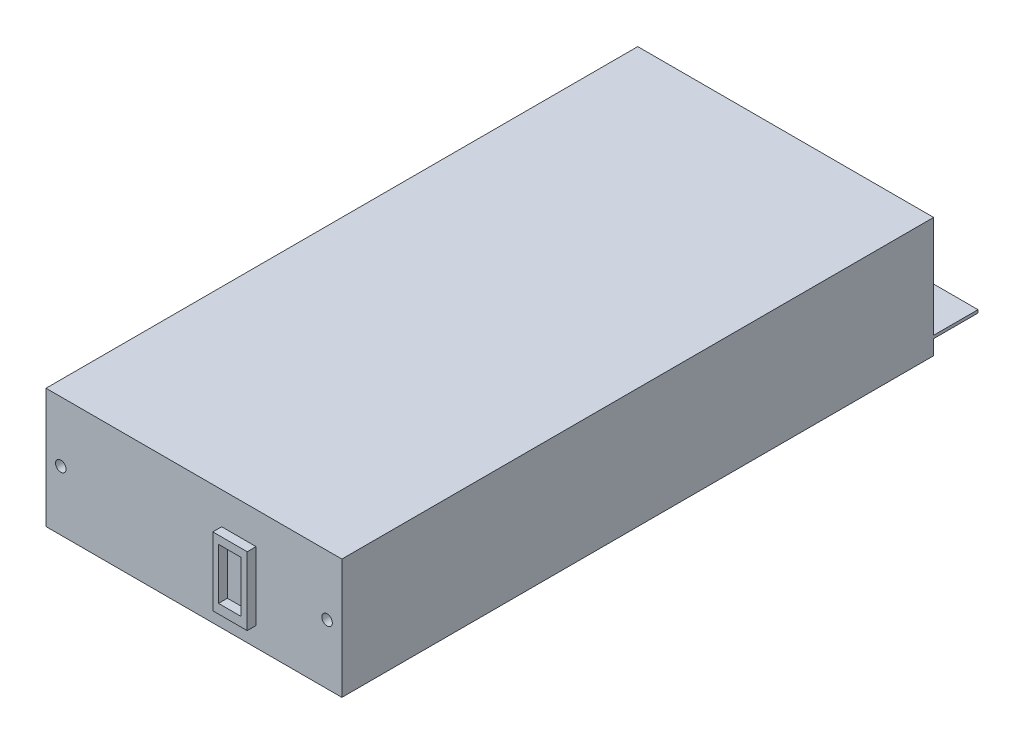
from build123d import *

# Parameters (mm, degrees)
SKETCH1_W          = 100
SKETCH1_H          = 40.5
EXTRUDE1_DEPTH     = 200
SKETCH2_R          = 1.778
CUT_EXTRUDE1_DEPTH = 10
SKETCH3_W          = 100
SKETCH3_H          = 1
EXTRUDE2_DEPTH     = 15
SKETCH4_R          = 1.778
CUT_EXTRUDE2_DEPTH = 15
SKETCH5_W          = 11.629297252
SKETCH5_H          = 23.097430101
EXTRUDE3_DEPTH     = 3
SKETCH6_W          = 7.618566084
SKETCH6_H          = 17.291576956
CUT_EXTRUDE3_DEPTH = 3


with BuildPart() as part:
    # Sketch1 → Extrude1 (new body)
    with BuildSketch(Plane.XY):
        with Locations((50, -20.25)):
            Rectangle(SKETCH1_W, SKETCH1_H)
    extrude(amount=EXTRUDE1_DEPTH)

    # Sketch2 → Cut-Extrude1 (cut)
    with BuildSketch(Plane.XY.offset(200)):
        with Locations((95, -20.3)):
            Circle(SKETCH2_R)
        with Locations((5, -20.3)):
            Circle(SKETCH2_R)
    extrude(amount=-CUT_EXTRUDE1_DEPTH, mode=Mode.SUBTRACT)

    # Sketch3 → Extrude2 (add)
    with BuildSketch(Plane(origin=(0, 0, 0), x_dir=(-1, 0, 0), z_dir=(0, 0, -1))):
        with Locations((-50, -35)):
            Rectangle(SKETCH3_W, SKETCH3_H)
    extrude(amount=EXTRUDE2_DEPTH)

    # Sketch4 → Cut-Extrude2 (cut)
    with BuildSketch(Plane(origin=(0, -34.5, 0), x_dir=(-1, 0, 0), z_dir=(0, 1, 0))):
        with Locations((-15, -11)):
            Circle(SKETCH4_R)
        with Locations((-85, -11)):
            Circle(SKETCH4_R)
    extrude(amount=-CUT_EXTRUDE2_DEPTH, mode=Mode.SUBTRACT)

    # Sketch5 → Extrude3 (add)
    with BuildSketch(Plane.XY.offset(200)):
        with Locations((65.188803726, -22.404247031)):
            Rectangle(SKETCH5_W, SKETCH5_H)
    extrude(amount=EXTRUDE3_DEPTH)

    # Sketch6 → Cut-Extrude3 (cut)
    with BuildSketch(Plane.XY.offset(203)):
        with Locations((65.10872937, -22.176041988)):
            Rectangle(SKETCH6_W, SKETCH6_H)
    extrude(amount=-CUT_EXTRUDE3_DEPTH, mode=Mode.SUBTRACT)


solid = part.part
